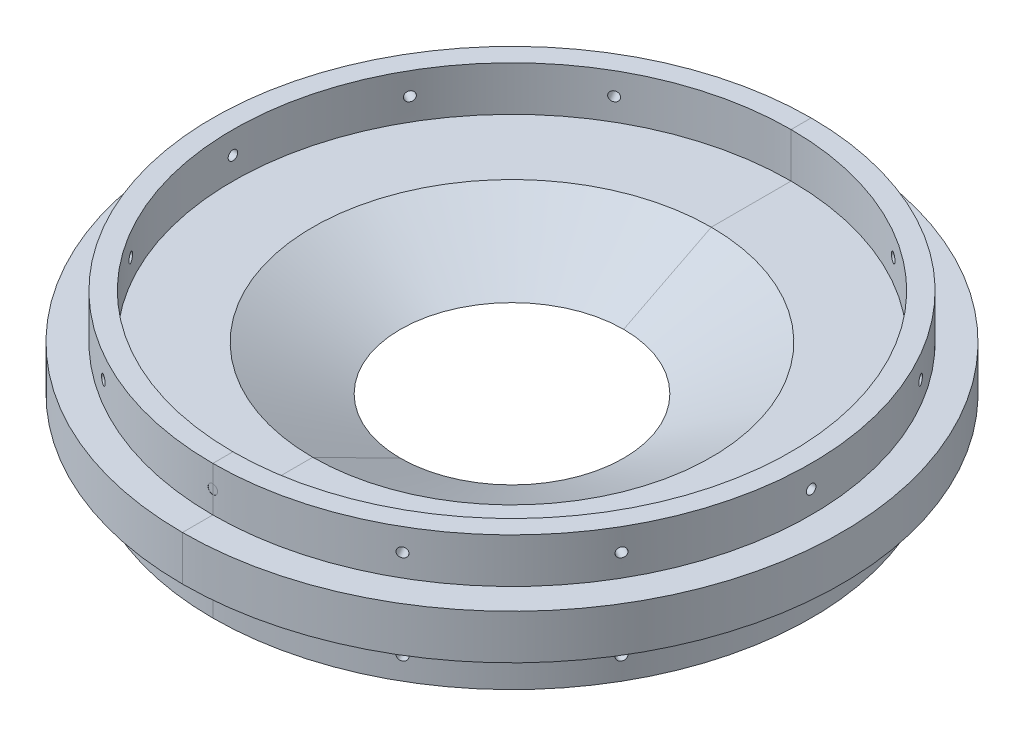
from build123d import *

# Parameters (mm, degrees)
SKETCH1_R                = 93.726
SKETCH1_R_2              = 31.75
BOSS_EXTRUDE1_DEPTH      = 6.35
SKETCH5_R                = 85.09
SKETCH5_R_2              = 79.375
BOSS_EXTRUDE2_DEPTH      = 12.7
SKETCH6_R                = 1.35255
CUT_EXTRUDE1_DEPTH       = 12.7
CIRPATTERN1_COUNT        = 12
MIRROR1_COPY_1_SKETCH_R  = 1.35255
MIRROR1_COPY_1_DEPTH     = 12.7
MIRROR1_COPY_2_SKETCH_R  = 1.35255
MIRROR1_COPY_2_DEPTH     = 12.7
MIRROR1_COPY_3_SKETCH_R  = 1.35255
MIRROR1_COPY_3_DEPTH     = 12.7
MIRROR1_COPY_4_SKETCH_R  = 1.35255
MIRROR1_COPY_4_DEPTH     = 12.7
MIRROR1_COPY_5_SKETCH_R  = 1.35255
MIRROR1_COPY_5_DEPTH     = 12.7
MIRROR1_COPY_6_SKETCH_R  = 1.35255
MIRROR1_COPY_6_DEPTH     = 12.7
MIRROR1_COPY_7_SKETCH_R  = 1.35255
MIRROR1_COPY_7_DEPTH     = 12.7
MIRROR1_COPY_8_SKETCH_R  = 1.35255
MIRROR1_COPY_8_DEPTH     = 12.7
MIRROR1_COPY_9_SKETCH_R  = 1.35255
MIRROR1_COPY_9_DEPTH     = 12.7
MIRROR1_COPY_10_SKETCH_R = 1.35255
MIRROR1_COPY_10_DEPTH    = 12.7
MIRROR1_COPY_11_SKETCH_R = 1.35255
MIRROR1_COPY_11_DEPTH    = 12.7
BOSS_EXTRUDE3_REACH      = 139.916
MIRROR5_COPY_1_REACH     = 139.916
MIRROR5_COPY_2_REACH     = 139.916


with BuildPart() as part:
    # Sketch1 → Boss-Extrude1 (new, symmetric)
    with BuildSketch(Plane(origin=(0, 0, 0), x_dir=(1, 0, 0), z_dir=(0, 1, 0))):
        with Locations(Location((0, 0, 0), (0, 0, 270))):
            Circle(SKETCH1_R)
        with Locations(Location((0, 0, 0), (0, 0, 270))):
            Circle(SKETCH1_R_2, mode=Mode.SUBTRACT)
    extrude(amount=BOSS_EXTRUDE1_DEPTH, both=True)

    # Sketch5 → Boss-Extrude2 (add)
    with BuildSketch(Plane(origin=(0, 6.35, 0), x_dir=(1, 0, 0), z_dir=(0, 1, 0))):
        with Locations(Location((0, 0, 0), (0, 0, 270))):
            Circle(SKETCH5_R)
        with Locations(Location((0, 0, 0), (0, 0, 270))):
            Circle(SKETCH5_R_2, mode=Mode.SUBTRACT)
    boss_extrude2 = extrude(amount=BOSS_EXTRUDE2_DEPTH)

    # Sketch6 → Cut-Extrude1 (cut)
    with BuildSketch(Plane(origin=(0, 0, -85.09), x_dir=(-1, 0, 0), z_dir=(0, 0, -1))):
        with Locations(Location((0, 12.7, 0), (0, 0, 90))):
            Circle(SKETCH6_R)
    cut_extrude1 = extrude(amount=-CUT_EXTRUDE1_DEPTH, mode=Mode.SUBTRACT)

    # CirPattern1: Cut-Extrude1 ×12 about axis
    cirpattern1_axis = Axis((0, 6.35, 0), (0, -1, 0))
    for i in range(1, CIRPATTERN1_COUNT):
        add(cut_extrude1.rotate(cirpattern1_axis, i * 360 / CIRPATTERN1_COUNT), mode=Mode.SUBTRACT)

    # Mirror1: Boss-Extrude2, Cut-Extrude1 across plane
    add(boss_extrude2.mirror(Plane.ZX))
    add(cut_extrude1.mirror(Plane.ZX), mode=Mode.SUBTRACT)

    # Mirror1 copy 1 sketch → Mirror1 copy 1 (cut)
    with BuildSketch(Plane(origin=(42.545, 0, -73.690101608), x_dir=(-0.8660254037844387, 0, -0.49999999999999994), z_dir=(0.49999999999999994, 0, -0.8660254037844387))):
        with Locations((0, -12.7)):
            Circle(MIRROR1_COPY_1_SKETCH_R)
    extrude(amount=-MIRROR1_COPY_1_DEPTH, mode=Mode.SUBTRACT)

    # Mirror1 copy 2 sketch → Mirror1 copy 2 (cut)
    with BuildSketch(Plane(origin=(73.690101608, 0, -42.545), x_dir=(-0.5000000000000001, 0, -0.8660254037844386), z_dir=(0.8660254037844386, 0, -0.5000000000000001))):
        with Locations((0, -12.7)):
            Circle(MIRROR1_COPY_2_SKETCH_R)
    extrude(amount=-MIRROR1_COPY_2_DEPTH, mode=Mode.SUBTRACT)

    # Mirror1 copy 3 sketch → Mirror1 copy 3 (cut)
    with BuildSketch(Plane(origin=(85.09, 0, 0), x_dir=(0, 0, -1), z_dir=(1, 0, 0))):
        with Locations((0, -12.7)):
            Circle(MIRROR1_COPY_3_SKETCH_R)
    extrude(amount=-MIRROR1_COPY_3_DEPTH, mode=Mode.SUBTRACT)

    # Mirror1 copy 4 sketch → Mirror1 copy 4 (cut)
    with BuildSketch(Plane(origin=(73.690101608, 0, 42.545), x_dir=(0.4999999999999998, 0, -0.8660254037844387), z_dir=(0.8660254037844387, 0, 0.4999999999999998))):
        with Locations((0, -12.7)):
            Circle(MIRROR1_COPY_4_SKETCH_R)
    extrude(amount=-MIRROR1_COPY_4_DEPTH, mode=Mode.SUBTRACT)

    # Mirror1 copy 5 sketch → Mirror1 copy 5 (cut)
    with BuildSketch(Plane(origin=(42.545, 0, 73.690101608), x_dir=(0.8660254037844387, 0, -0.49999999999999994), z_dir=(0.49999999999999994, 0, 0.8660254037844387))):
        with Locations((0, -12.7)):
            Circle(MIRROR1_COPY_5_SKETCH_R)
    extrude(amount=-MIRROR1_COPY_5_DEPTH, mode=Mode.SUBTRACT)

    # Mirror1 copy 6 sketch → Mirror1 copy 6 (cut)
    with BuildSketch(Plane.XY.offset(85.09)):
        with Locations((0, -12.7)):
            Circle(MIRROR1_COPY_6_SKETCH_R)
    extrude(amount=-MIRROR1_COPY_6_DEPTH, mode=Mode.SUBTRACT)

    # Mirror1 copy 7 sketch → Mirror1 copy 7 (cut)
    with BuildSketch(Plane(origin=(-42.545, 0, 73.690101608), x_dir=(0.8660254037844386, 0, 0.5000000000000001), z_dir=(-0.5000000000000001, 0, 0.8660254037844386))):
        with Locations((0, -12.7)):
            Circle(MIRROR1_COPY_7_SKETCH_R)
    extrude(amount=-MIRROR1_COPY_7_DEPTH, mode=Mode.SUBTRACT)

    # Mirror1 copy 8 sketch → Mirror1 copy 8 (cut)
    with BuildSketch(Plane(origin=(-73.690101608, 0, 42.545), x_dir=(0.5000000000000004, 0, 0.8660254037844384), z_dir=(-0.8660254037844384, 0, 0.5000000000000004))):
        with Locations((0, -12.7)):
            Circle(MIRROR1_COPY_8_SKETCH_R)
    extrude(amount=-MIRROR1_COPY_8_DEPTH, mode=Mode.SUBTRACT)

    # Mirror1 copy 9 sketch → Mirror1 copy 9 (cut)
    with BuildSketch(Plane.ZY.offset(85.09)):
        with Locations((0, -12.7)):
            Circle(MIRROR1_COPY_9_SKETCH_R)
    extrude(amount=-MIRROR1_COPY_9_DEPTH, mode=Mode.SUBTRACT)

    # Mirror1 copy 10 sketch → Mirror1 copy 10 (cut)
    with BuildSketch(Plane(origin=(-73.690101608, 0, -42.545), x_dir=(-0.5000000000000001, 0, 0.8660254037844386), z_dir=(-0.8660254037844386, 0, -0.5000000000000001))):
        with Locations((0, -12.7)):
            Circle(MIRROR1_COPY_10_SKETCH_R)
    extrude(amount=-MIRROR1_COPY_10_DEPTH, mode=Mode.SUBTRACT)

    # Mirror1 copy 11 sketch → Mirror1 copy 11 (cut)
    with BuildSketch(Plane(origin=(-42.545, 0, -73.690101608), x_dir=(-0.8660254037844384, 0, 0.5000000000000004), z_dir=(-0.5000000000000004, 0, -0.8660254037844384))):
        with Locations((0, -12.7)):
            Circle(MIRROR1_COPY_11_SKETCH_R)
    extrude(amount=-MIRROR1_COPY_11_DEPTH, mode=Mode.SUBTRACT)

    # Boss-Extrude3: up to this face of the body (flat: up to its plane)
    boss_extrude3_end = Plane(part.part.faces().sort_by_distance((0, 6.35, -91.075028393))[0])
    # Sketch7 → Boss-Extrude3 (add, up to the picked face)
    with BuildSketch(Plane(origin=(0, 19.05, 0), x_dir=(1, 0, 0), z_dir=(0, 1, 0)), mode=Mode.PRIVATE) as boss_extrude3_sk1:
        with BuildLine():
            Line((-25.787822327, 75.06916041), (-27.957618348, 80.365911158))
            ThreePointArc((-27.957618348, 80.365911158), (0, 85.052974355), (27.957618348, 80.365911158))
            Line((27.957618348, 80.365911158), (25.787822327, 75.06916041))
            ThreePointArc((25.787822327, 75.06916041), (0, 79.375), (-25.787822327, 75.06916041))
        make_face()
    boss_extrude3_tool1 = split(extrude(boss_extrude3_sk1.sketch, amount=-BOSS_EXTRUDE3_REACH, mode=Mode.PRIVATE), bisect_by=boss_extrude3_end, keep=Keep.BOTH, mode=Mode.PRIVATE)
    boss_extrude3 = boss_extrude3_tool1.solids().sort_by(Axis((0, 19.05, -80.744502), (0, -1, 0)))[0]
    add(boss_extrude3)

    # Mirror3: Boss-Extrude3 across plane
    add(boss_extrude3.mirror(Plane.ZX))

    # Mirror4: Boss-Extrude3 across plane
    add(boss_extrude3.mirror(Plane.XY))

    # Mirror5 copy 1: up to this face of the body (flat: up to its plane)
    mirror5_copy_1_end = Plane(part.part.faces().sort_by_distance((0, -6.35, 91.075028393))[0])
    # Mirror5 copy 1 sketch → Mirror5 copy 1 (add, up to the picked face)
    with BuildSketch(Plane.XZ.offset(19.05), mode=Mode.PRIVATE) as mirror5_copy_1_sk1:
        with BuildLine():
            Line((-25.787822327, 75.06916041), (-27.957618348, 80.365911158))
            ThreePointArc((-27.957618348, 80.365911158), (0, 85.052974355), (27.957618348, 80.365911158))
            Line((27.957618348, 80.365911158), (25.787822327, 75.06916041))
            ThreePointArc((25.787822327, 75.06916041), (0, 79.375), (-25.787822327, 75.06916041))
        make_face()
    mirror5_copy_1_tool1 = split(extrude(mirror5_copy_1_sk1.sketch, amount=-MIRROR5_COPY_1_REACH, mode=Mode.PRIVATE), bisect_by=mirror5_copy_1_end, keep=Keep.BOTH, mode=Mode.PRIVATE)
    add(mirror5_copy_1_tool1.solids().sort_by(Axis((0, -19.05, 80.744502), (0, 1, 0)))[0])

    # Mirror5 copy 2: up to this face of the body (flat: up to its plane)
    mirror5_copy_2_end = Plane(part.part.faces().sort_by_distance((0, -6.35, -91.075028393))[0])
    # Mirror5 copy 2 sketch → Mirror5 copy 2 (add, up to the picked face)
    with BuildSketch(Plane.XZ.offset(19.05), mode=Mode.PRIVATE) as mirror5_copy_2_sk1:
        with BuildLine():
            Line((-25.787822327, -75.06916041), (-27.957618348, -80.365911158))
            ThreePointArc((-27.957618348, -80.365911158), (0, -85.052974355), (27.957618348, -80.365911158))
            Line((27.957618348, -80.365911158), (25.787822327, -75.06916041))
            ThreePointArc((25.787822327, -75.06916041), (0, -79.375), (-25.787822327, -75.06916041))
        make_face()
    mirror5_copy_2_tool1 = split(extrude(mirror5_copy_2_sk1.sketch, amount=-MIRROR5_COPY_2_REACH, mode=Mode.PRIVATE), bisect_by=mirror5_copy_2_end, keep=Keep.BOTH, mode=Mode.PRIVATE)
    add(mirror5_copy_2_tool1.solids().sort_by(Axis((0, -19.05, -80.744502), (0, 1, 0)))[0])

    # Sketch3 → Cut-Revolve1 (revolve, cut)
    with BuildSketch(Plane.XY, mode=Mode.PRIVATE) as cut_revolve1_sk:
        Polygon((-31.75, -6.35), (-56.67515342, 6.35), (-31.75, 6.35), align=None)
    revolve(cut_revolve1_sk.sketch.rotate(Axis((0, 23.278593151, 0), (0, -1, 0)), 270), axis=Axis((0, 23.278593151, 0), (0, -1, 0)), mode=Mode.SUBTRACT)


with BuildPart() as body_2:
    # Split1: the piece on the far side of the plane
    add(part.part)
    split(bisect_by=Plane(origin=(0, 0, 0), x_dir=(0, 0, 1), z_dir=(1, 0, 0)), keep=Keep.BOTTOM)


with BuildPart() as part_1:
    add(part.part)

    # Split1
    split(bisect_by=Plane(origin=(0, 0, 0), x_dir=(0, 0, 1), z_dir=(1, 0, 0)), keep=Keep.TOP)


solid = Compound([body_2.part, part_1.part])
